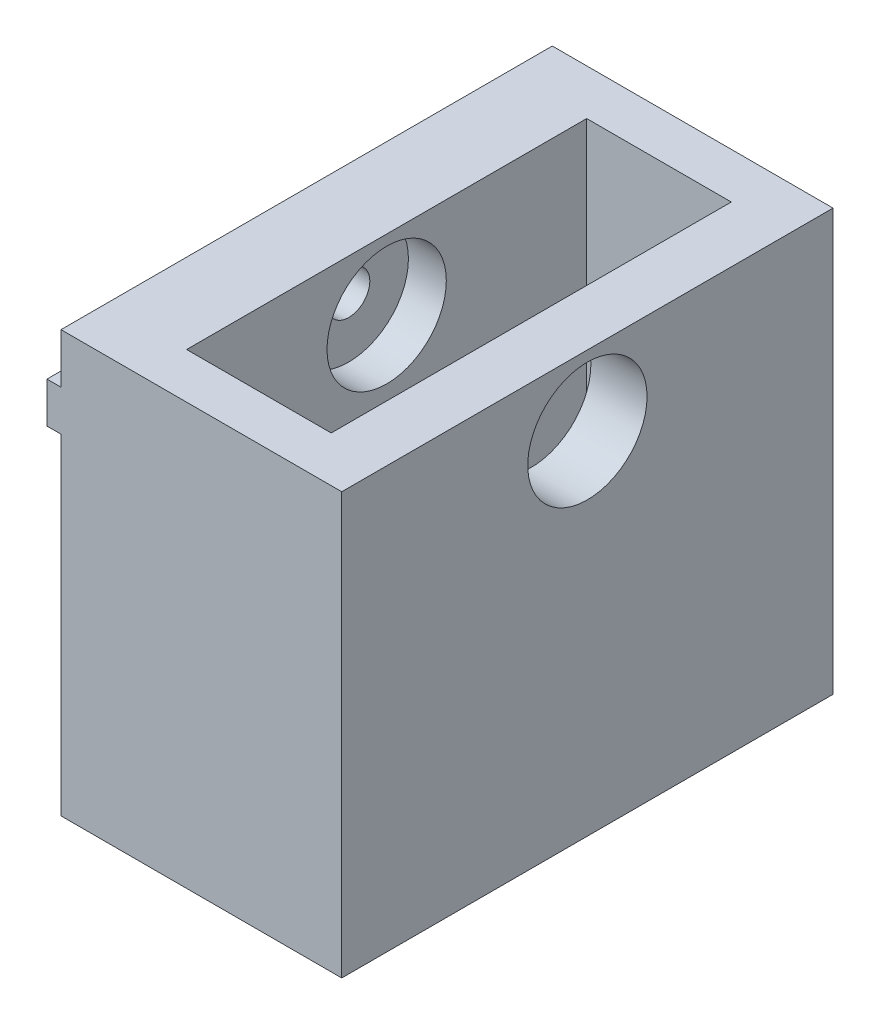
from build123d import *

# Parameters (mm, degrees)
MAIN_DEPTH             = 17.5
SKETCH2_W              = 10.3
SKETCH2_H              = 28.5
HOLEFORSWITCH_DEPTH    = 31
SKETCH4_R              = 1.5
MAKERBEAMFIXHOLE_DEPTH = 22
HOLEFORTOOL_START      = -17
SKETCH5_R              = 4.25
HOLEFORTOOL_DEPTH      = 17


with BuildPart() as part:
    # Sketch1 → Main (new body, symmetric)
    with BuildSketch(Plane.XY):
        Polygon((-1, 26.45), (-1, 23.55), (0, 23.55), (0, 0), (20, 0), (20, 30), (0, 30), (0, 26.45), align=None)
    extrude(amount=MAIN_DEPTH, both=True)

    # Sketch2 → HoleForSwitch (cut, through all)
    with BuildSketch(Plane(origin=(0, 30, 0), x_dir=(1, 0, 0), z_dir=(0, 1, 0))):
        with Locations((10.85, 0)):
            Rectangle(SKETCH2_W, SKETCH2_H)
    extrude(amount=-HOLEFORSWITCH_DEPTH, mode=Mode.SUBTRACT)

    # Sketch4 → MakerBeamFixHole (cut, through all)
    with BuildSketch(Plane.ZY.offset(1)):
        with Locations((0, 25)):
            Circle(SKETCH4_R)
    extrude(amount=-MAKERBEAMFIXHOLE_DEPTH, mode=Mode.SUBTRACT)

    # Sketch5 → HoleForTool (cut)
    with BuildSketch(Plane(origin=(20, 0, 0), x_dir=(0, 0, -1), z_dir=(1, 0, 0)).offset(HOLEFORTOOL_START)):
        with Locations((0, 25)):
            Circle(SKETCH5_R)
    extrude(amount=HOLEFORTOOL_DEPTH, mode=Mode.SUBTRACT)


solid = part.part
